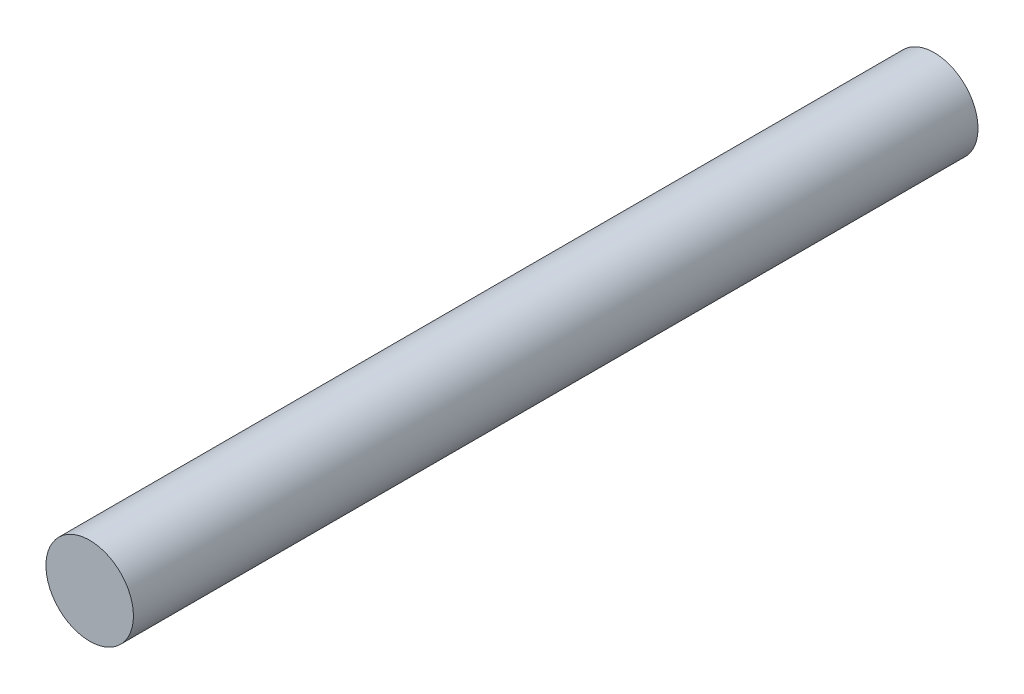
from build123d import *

# Parameters (mm, degrees)
SKETCH1_R           = 2.5
BOSS_EXTRUDE1_DEPTH = 48.25


with BuildPart() as part:
    # Sketch1 → Boss-Extrude1 (new body)
    with BuildSketch(Plane.XY):
        Circle(SKETCH1_R)
    extrude(amount=BOSS_EXTRUDE1_DEPTH)


solid = part.part
